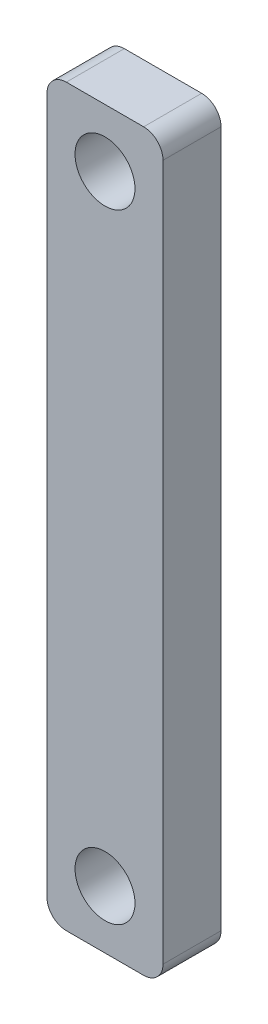
from build123d import *

# Parameters (mm, degrees)
ESQUISSE1_W        = 6
ESQUISSE1_H        = 38
ESQUISSE1_R        = 1.55
BOSS_EXTRU_1_DEPTH = 3
CONG_1_R           = 1


with BuildPart() as part:
    # Esquisse1 → Boss.-Extru.1 (new body)
    with BuildSketch(Plane.XY):
        Rectangle(ESQUISSE1_W, ESQUISSE1_H)
        with Locations((0, 16)):
            Circle(ESQUISSE1_R, mode=Mode.SUBTRACT)
        with Locations((0, -16)):
            Circle(ESQUISSE1_R, mode=Mode.SUBTRACT)
    extrude(amount=BOSS_EXTRU_1_DEPTH)

    # Congé1
    cong_1_edges = [part.edges().sort_by_distance(p)[0] for p in [
        (3, -19, 1.5),
        (-3, -19, 1.5),
        (-3, 19, 1.5),
        (3, 19, 1.5),
    ]]
    fillet(cong_1_edges, radius=CONG_1_R)


solid = part.part
